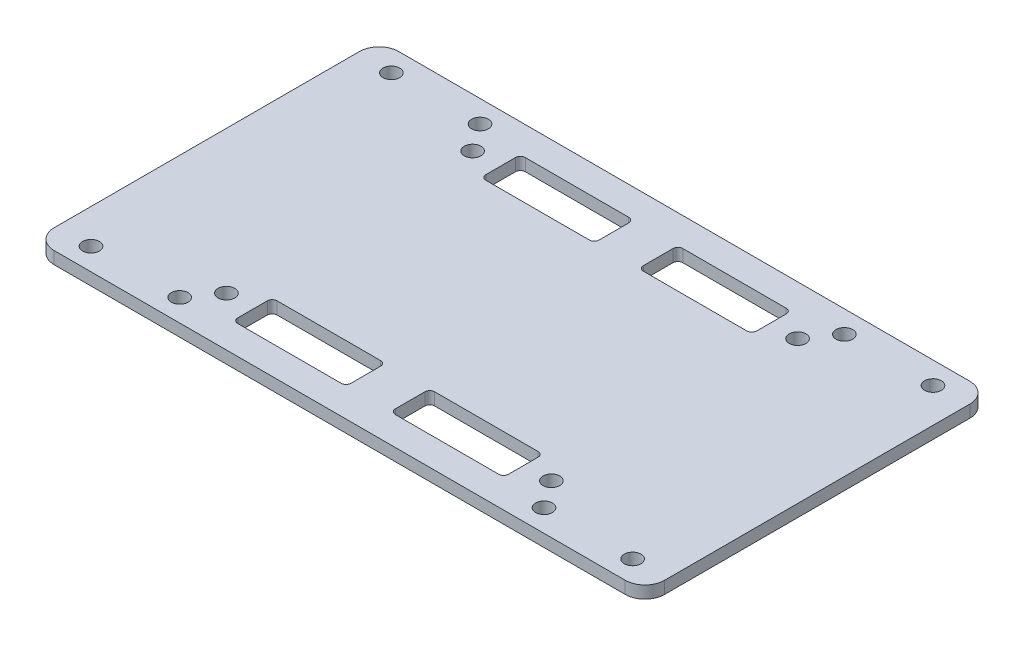
from build123d import *

# Parameters (mm, degrees)
SKETCH_1_W      = 124
SKETCH_1_H      = 70
SKETCH_1_R      = 1.7
SKETCH_1_W_2    = 23
SKETCH_1_H_2    = 8
EXTRUDE_1_DEPTH = 2.5
FILLET_1_R      = 4
FILLET_2_R      = 4
FILLET_3_R      = 4
FILLET_4_R      = 4
FILLET_6_R      = 1
FILLET_8_R      = 1
FILLET_9_R      = 1


with BuildPart() as part:
    # 草图1 → 凸台-拉伸1 (new body)
    with BuildSketch(Plane(origin=(0, 0, 0), x_dir=(1, 0, 0), z_dir=(0, 1, 0))):
        with Locations((-5.316321244, -0.475281048)):
            Rectangle(SKETCH_1_W, SKETCH_1_H)
        with Locations((49.683678756, -30.975281048)):
            Circle(SKETCH_1_R, mode=Mode.SUBTRACT)
        with Locations((49.683678756, 30.024718952)):
            Circle(SKETCH_1_R, mode=Mode.SUBTRACT)
        with Locations((-60.316321244, 30.024718952)):
            Circle(SKETCH_1_R, mode=Mode.SUBTRACT)
        with Locations((-60.316321244, -30.975281048)):
            Circle(SKETCH_1_R, mode=Mode.SUBTRACT)
        with Locations((-42.316321244, -30.975281048)):
            Circle(SKETCH_1_R, mode=Mode.SUBTRACT)
        with Locations((-38.316321244, -25.475281048)):
            Circle(SKETCH_1_R, mode=Mode.SUBTRACT)
        with Locations((31.683678756, -30.975281048)):
            Circle(SKETCH_1_R, mode=Mode.SUBTRACT)
        with Locations((27.683678756, -25.475281048)):
            Circle(SKETCH_1_R, mode=Mode.SUBTRACT)
        with Locations((31.683678756, 30.024718952)):
            Circle(SKETCH_1_R, mode=Mode.SUBTRACT)
        with Locations((27.683678756, 24.524718952)):
            Circle(SKETCH_1_R, mode=Mode.SUBTRACT)
        with Locations((-42.316321244, 30.024718952)):
            Circle(SKETCH_1_R, mode=Mode.SUBTRACT)
        with Locations((-38.316321244, 24.524718952)):
            Circle(SKETCH_1_R, mode=Mode.SUBTRACT)
        with Locations((10.683678756, -25.675281048)):
            Rectangle(SKETCH_1_W_2, SKETCH_1_H_2, mode=Mode.SUBTRACT)
        with Locations((-21.316321244, -25.675281048)):
            Rectangle(SKETCH_1_W_2, SKETCH_1_H_2, mode=Mode.SUBTRACT)
        with Locations((-21.316321244, 24.724718952)):
            Rectangle(SKETCH_1_W_2, SKETCH_1_H_2, mode=Mode.SUBTRACT)
        with Locations((10.683678756, 24.724718952)):
            Rectangle(SKETCH_1_W_2, SKETCH_1_H_2, mode=Mode.SUBTRACT)
    extrude(amount=EXTRUDE_1_DEPTH)

    # 圆角1
    fillet_1_edges = [part.edges().sort_by_distance(p)[0] for p in [
        (-67.316321244, 1.25, 35.475281048),
    ]]
    fillet(fillet_1_edges, radius=FILLET_1_R)

    # 圆角2
    fillet_2_edges = [part.edges().sort_by_distance(p)[0] for p in [
        (-67.316321244, 1.25, -34.524718952),
    ]]
    fillet(fillet_2_edges, radius=FILLET_2_R)

    # 圆角3
    fillet_3_edges = [part.edges().sort_by_distance(p)[0] for p in [
        (56.683678756, 1.25, 35.475281048),
    ]]
    fillet(fillet_3_edges, radius=FILLET_3_R)

    # 圆角4
    fillet_4_edges = [part.edges().sort_by_distance(p)[0] for p in [
        (56.683678756, 1.25, -34.524718952),
    ]]
    fillet(fillet_4_edges, radius=FILLET_4_R)

    # 圆角6
    fillet_6_edges = [part.edges().sort_by_distance(p)[0] for p in [
        (-0.816321244, 1.25, -28.724718952),
        (-0.816321244, 1.25, -20.724718952),
        (22.183678756, 1.25, -20.724718952),
        (22.183678756, 1.25, -28.724718952),
    ]]
    fillet(fillet_6_edges, radius=FILLET_6_R)

    # 圆角8
    fillet_8_edges = [part.edges().sort_by_distance(p)[0] for p in [
        (-32.816321244, 1.25, -28.724718952),
        (-32.816321244, 1.25, -20.724718952),
        (-9.816321244, 1.25, -20.724718952),
        (-9.816321244, 1.25, -28.724718952),
    ]]
    fillet(fillet_8_edges, radius=FILLET_8_R)

    # 圆角9
    fillet_9_edges = [part.edges().sort_by_distance(p)[0] for p in [
        (-32.816321244, 1.25, 21.675281048),
        (-32.816321244, 1.25, 29.675281048),
        (-9.816321244, 1.25, 29.675281048),
        (-9.816321244, 1.25, 21.675281048),
        (-0.816321244, 1.25, 21.675281048),
        (-0.816321244, 1.25, 29.675281048),
        (22.183678756, 1.25, 29.675281048),
        (22.183678756, 1.25, 21.675281048),
    ]]
    fillet(fillet_9_edges, radius=FILLET_9_R)


solid = part.part
